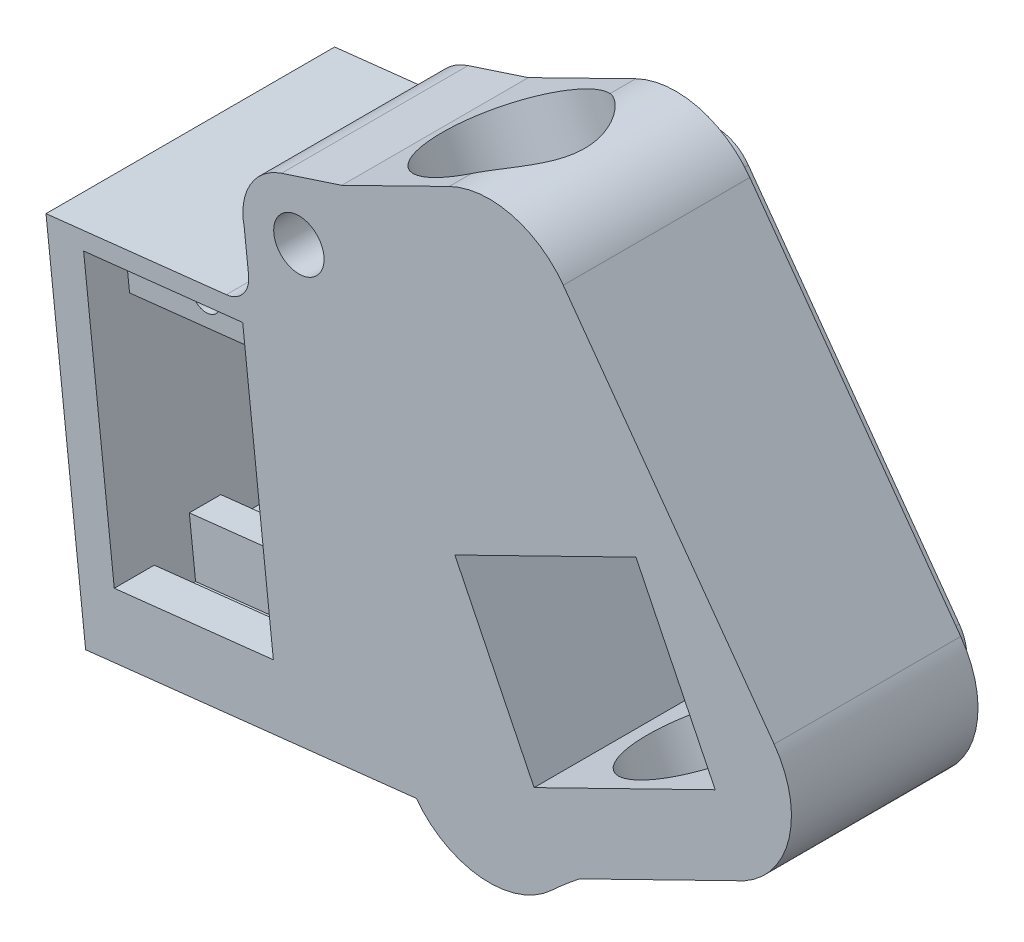
from build123d import *

# Parameters (mm, degrees)
BOSS_EXTRUDE1_DEPTH      = 15.06
BOSS_EXTRUDE2_DEPTH      = 3.175
SKETCH7_W                = 15.06
SKETCH7_H                = 28.575
BOSS_EXTRUDE3_DEPTH      = 25.4
BOSS_EXTRUDE3_DEPTH_BACK = 2.54
CUT_EXTRUDE1_START       = -0.254
CUT_EXTRUDE1_DEPTH       = 14.552
BOSS_EXTRUDE4_DEPTH      = 8.1
SKETCH8_R                = 5.1
CUT_EXTRUDE3_DEPTH       = 826.597233992
SKETCH15_R               = 6.096
CUT_EXTRUDE4_DEPTH       = 823.185140665
CUT_EXTRUDE6_DEPTH       = 0.254
SKETCH22_W               = 12.7
SKETCH22_H               = 3
CUT_EXTRUDE8_DEPTH       = 2.5
BOSS_EXTRUDE5_START      = -3.175
SKETCH23_R               = 1.13
BOSS_EXTRUDE5_DEPTH      = 11.377
CUT_EXTRUDE9_DEPTH       = 2
SKETCH25_W               = 12.7
SKETCH25_H               = 2.5
BOSS_EXTRUDE6_DEPTH      = 2
CUT_EXTRUDE11_DEPTH      = 826.590147754
BOSS_EXTRUDE7_DEPTH      = 19.886
FILLET1_R                = 2
SKETCH31_R               = 2
CUT_EXTRUDE12_DEPTH      = 826.405127723


with BuildPart() as part:
    # Sketch1 → Boss-Extrude1 (new body)
    with BuildSketch(Plane.XY):
        with BuildLine():
            ThreePointArc((768.898502001, 253.220496825), (772.473384001, 257.975032047), (771.279316377, 263.802517698))
            Line((771.279316377, 263.802517698), (754.541770866, 286.976250421))
            ThreePointArc((754.541770866, 286.976250421), (750.425558167, 289.761469174), (745.483441324, 289.235986934))
            Line((745.483441324, 289.235986934), (736.959388492, 285.051606769))
            Line((736.959388492, 285.051606769), (732.179744734, 283.489883627))
            ThreePointArc((732.179744734, 283.489883627), (729.115297933, 279.264699802), (732.179762843, 275.03952911))
            Line((732.179762843, 275.03952911), (736.959413295, 273.477826454))
            ThreePointArc((736.959413295, 273.477826454), (738.543478356, 272.323947498), (739.148316802, 270.459847389))
            Line((739.148316802, 270.459847389), (741.478441562, 249.420712606))
            ThreePointArc((741.478441562, 249.420712606), (746.159744473, 243.429023652), (753.614349117, 244.926956583))
            ThreePointArc((753.614349117, 244.926956583), (754.705448313, 245.901255726), (755.838945539, 246.825885552))
            Line((755.838945539, 246.825885552), (768.898502001, 253.220496825))
        make_face()
    extrude(amount=BOSS_EXTRUDE1_DEPTH)

    # Sketch1_4 → Boss-Extrude2 (add)
    with BuildSketch(Plane.XY):
        with BuildLine():
            Line((767.984780823, 261.422994326), (751.247235317, 284.596727042))
            ThreePointArc((751.247235317, 284.596727042), (747.696485062, 285.758701464), (745.498379419, 282.7377176))
            Line((745.498379419, 282.7377176), (745.498449109, 250.217566764))
            ThreePointArc((745.498449109, 250.217566764), (747.408500645, 247.30543855), (750.840510516, 247.897127523))
            ThreePointArc((750.840510516, 247.897127523), (758.022031433, 253.136086658), (766.249615232, 256.501766428))
            ThreePointArc((766.249615232, 256.501766428), (768.405251042, 258.508228422), (767.984780823, 261.422994326))
        make_face()
    extrude(amount=-BOSS_EXTRUDE2_DEPTH)

    # Sketch7 → Boss-Extrude3 (add, two sides)
    with BuildSketch(Plane(origin=(759.782778814, 84.147408332, 0), x_dir=(0, 0, 1), z_dir=(-0.9939228549686344, -0.11007887340901991, 0))) as boss_extrude3_sk:
        with Locations((7.53, 176.895767228)):
            Rectangle(SKETCH7_W, SKETCH7_H)
    extrude(amount=BOSS_EXTRUDE3_DEPTH)
    extrude(boss_extrude3_sk.sketch, amount=-BOSS_EXTRUDE3_DEPTH_BACK)

    # Sketch9 → Cut-Extrude1 (cut)
    with BuildSketch(Plane.XY.offset(15.06).offset(CUT_EXTRUDE1_START)):
        Polygon((731.533703152, 249.732332737), (729.101180207, 271.696039986), (716.478359949, 270.298038294), (718.910882894, 248.334331045), align=None)
    extrude(amount=-CUT_EXTRUDE1_DEPTH, mode=Mode.SUBTRACT)

    # Sketch11 → Boss-Extrude4 (add)
    with BuildSketch(Plane(origin=(0, 0, 0), x_dir=(-1, 0, 0), z_dir=(0, 0, -1))):
        with BuildLine():
            Line((-716.637403434, 242.971478152), (-713.491899626, 271.372823733))
            Line((-713.491899626, 271.372823733), (-735.830090144, 273.846821422))
            Line((-735.830090144, 273.846821422), (-736.959413295, 273.477826454))
            ThreePointArc((-736.959413295, 273.477826454), (-738.543478356, 272.323947498), (-739.148316802, 270.459847389))
            Line((-739.148316802, 270.459847389), (-739.148370366, 245.464611162))
            Line((-739.148370366, 245.464611162), (-716.637403434, 242.971478152))
        make_face()
    extrude(amount=BOSS_EXTRUDE4_DEPTH)

    # Sketch8 → Cut-Extrude3 (cut, through all)
    with BuildSketch(Plane.XY.offset(15.06)):
        with Locations((723.935575753, 257.835181621)):
            Circle(SKETCH8_R)
    extrude(amount=-CUT_EXTRUDE3_DEPTH, mode=Mode.SUBTRACT)

    # Sketch15 → Cut-Extrude4 (cut, through all)
    with BuildSketch(Plane(origin=(48.686517672, -99.431271016, 0), x_dir=(0.8981144857275971, 0.4397617201692911, 0), z_dir=(0.43976172016929105, -0.898114485727597, 0))):
        with Locations((794.095983967, 7.53212)):
            Circle(SKETCH15_R)
    extrude(amount=-CUT_EXTRUDE4_DEPTH, mode=Mode.SUBTRACT)

    # Sketch20 → Cut-Extrude6 (cut)
    with BuildSketch(Plane.XY.offset(15.06)):
        with BuildLine():
            Line((732.179762843, 275.03952911), (735.830090144, 273.846821422))
            Line((735.830090144, 273.846821422), (713.491899626, 271.372823733))
            Line((713.491899626, 271.372823733), (716.637403434, 242.971478152))
            Line((716.637403434, 242.971478152), (742.879500347, 245.877841005))
            ThreePointArc((742.879500347, 245.877841005), (748.034725116, 243.00680713), (753.614349117, 244.926956583))
            ThreePointArc((753.614349117, 244.926956583), (754.705448313, 245.901255726), (755.838945539, 246.825885552))
            Line((755.838945539, 246.825885552), (768.898502001, 253.220496825))
            ThreePointArc((768.898502001, 253.220496825), (772.473384001, 257.975032047), (771.279316377, 263.802517698))
            Line((771.279316377, 263.802517698), (754.541770866, 286.976250421))
            ThreePointArc((754.541770866, 286.976250421), (750.425558167, 289.761469174), (745.483441324, 289.235986934))
            Line((745.483441324, 289.235986934), (736.959388492, 285.051606769))
            Line((736.959388492, 285.051606769), (732.179744734, 283.489883627))
            ThreePointArc((732.179744734, 283.489883627), (729.115297933, 279.264699802), (732.179762843, 275.03952911))
        make_face()
        Polygon((718.910882894, 248.334331045), (731.533703152, 249.732332737), (729.101180207, 271.696039986), (716.478359949, 270.298038294), align=None, mode=Mode.SUBTRACT)
    extrude(amount=-CUT_EXTRUDE6_DEPTH, mode=Mode.SUBTRACT)


with BuildPart() as cut_extrude6_kept_piece:
    # of the separate pieces the step leaves, the one the design keeps (cut_extrude6_pieces_kept)
    add(part.part.solids().sort_by_distance((753.614349117, 244.926956583, 0))[0])

    # Sketch22 → Cut-Extrude8 (cut)
    with BuildSketch(Plane(origin=(-18.45893554, 166.669201308, 0), x_dir=(0.9939228549686345, 0.11007887340901987, 0), z_dir=(-0.11007887340901987, 0.9939228549686345, 0))):
        with Locations((748.228320584, -10.131)):
            Rectangle(SKETCH22_W, SKETCH22_H)
    extrude(amount=-CUT_EXTRUDE8_DEPTH, mode=Mode.SUBTRACT)

    # Sketch23 → Boss-Extrude5 (add)
    with BuildSketch(Plane.XY.offset(14.806).offset(BOSS_EXTRUDE5_START)):
        Polygon((716.94729595, 266.063926932), (729.570116208, 267.461928624), (729.101180207, 271.696039986), (716.478359949, 270.298038294), align=None)
        with Locations((723.024238078, 268.879983459)):
            Circle(SKETCH23_R, mode=Mode.SUBTRACT)
    extrude(amount=-BOSS_EXTRUDE5_DEPTH)

    # Sketch24 → Cut-Extrude9 (cut)
    with BuildSketch(Plane.XY.offset(0.254)):
        Polygon((716.94729595, 266.063926932), (717.27753257, 263.082158367), (729.900352828, 264.480160059), (729.570116208, 267.461928624), align=None)
    extrude(amount=-CUT_EXTRUDE9_DEPTH, mode=Mode.SUBTRACT)

    # Sketch25 → Boss-Extrude6 (add)
    with BuildSketch(Plane(origin=(-18.45893554, 166.669201308, 0), x_dir=(0.9939228549686345, 0.11007887340901987, 0), z_dir=(-0.11007887340901987, 0.9939228549686345, 0))):
        with Locations((748.228320584, -7.381)):
            Rectangle(SKETCH25_W, SKETCH25_H)
    extrude(amount=BOSS_EXTRUDE6_DEPTH)

    # Sketch29 → Cut-Extrude11 (cut, through all)
    with BuildSketch(Plane.XY.offset(14.806)):
        Polygon((752.228042412, 251.293092232), (766.597874183, 258.329279755), (760.309281585, 271.1723169), (745.939449813, 264.136129378), align=None)
    extrude(amount=-CUT_EXTRUDE11_DEPTH, mode=Mode.SUBTRACT)

    # Sketch30 → Boss-Extrude7 (add)
    with BuildSketch(Plane.XY.offset(14.806)):
        with BuildLine():
            Line((729.789433052, 273.177806997), (735.830090144, 273.846821422))
            Line((735.830090144, 273.846821422), (732.179762843, 275.03952911))
            ThreePointArc((732.179762843, 275.03952911), (730.271210596, 276.27473784), (729.223019165, 278.292064539))
            Line((729.223019165, 278.292064539), (729.789433052, 273.177806997))
        make_face()
    extrude(amount=-BOSS_EXTRUDE7_DEPTH)

    # Fillet1
    fillet1_edges = [cut_extrude6_kept_piece.edges().sort_by_distance(p)[0] for p in [
        (729.789433052, 273.177806997, 4.863),
    ]]
    fillet(fillet1_edges, radius=FILLET1_R)

    # Sketch31 → Cut-Extrude12 (cut, through all)
    with BuildSketch(Plane(origin=(0, 0, 0), x_dir=(-1, 0, 0), z_dir=(0, 0, -1))):
        with Locations((-733.560297933, 279.264709327)):
            Circle(SKETCH31_R)
    extrude(amount=-CUT_EXTRUDE12_DEPTH, mode=Mode.SUBTRACT)


solid = cut_extrude6_kept_piece.part
